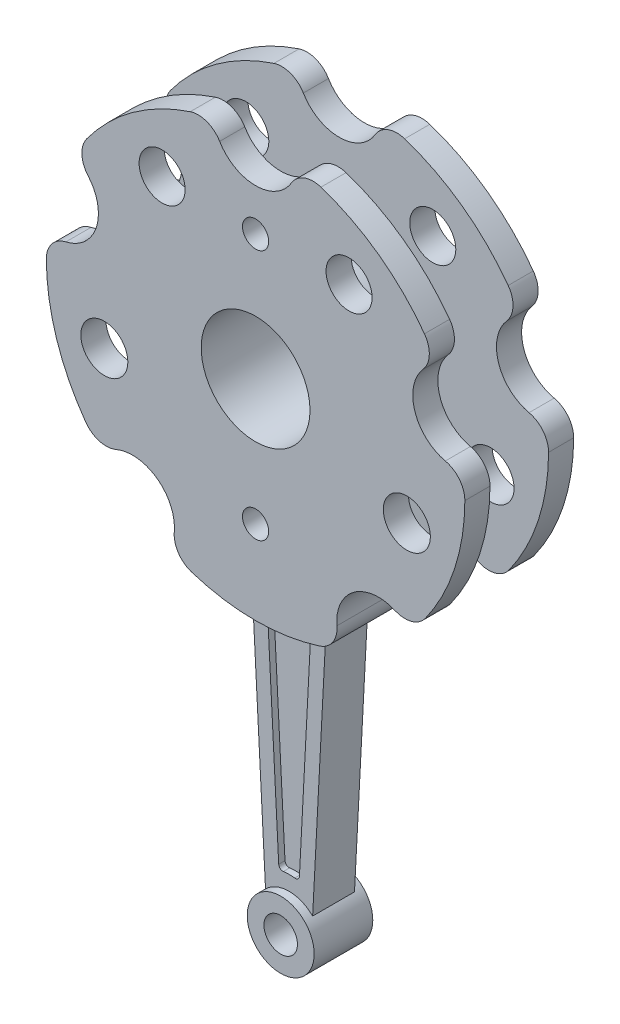
from build123d import *

# Parameters (mm, degrees)
SKETCH1_R           = 13
SKETCH1_R_2         = 3.125
SKETCH1_R_3         = 5.5
SKETCH1_R_4         = 5.616805682
BOSS_EXTRUDE2_DEPTH = 13
SKETCH3_OUTSIDE_W   = 130.454
SKETCH3_OUTSIDE_H   = 128.254
CUT_EXTRUDE2_DEPTH  = 7
BOSS_EXTRUDE3_DEPTH = 3.5
BOSS_EXTRUDE4_DEPTH = 5
SKETCH6_R           = 4
BOSS_EXTRUDE5_DEPTH = 7


with BuildPart() as part:
    # Sketch1 → Boss-Extrude2 (new body, symmetric)
    with BuildSketch(Plane.XY):
        with BuildLine():
            ThreePointArc((45.332150622, 5.700536817), (48.696221254, 3.58439722), (49.999710802, -0.170057869))
            ThreePointArc((49.999710802, -0.170057869), (47.552825815, -15.450849719), (40.55057326, -29.251512923))
            ThreePointArc((40.55057326, -29.251512923), (37.289214732, -31.522758961), (33.323788774, -31.257400752))
            ThreePointArc((33.323788774, -31.257400752), (23.511410092, -32.360679775), (19.42993762, -41.351874493))
            ThreePointArc((19.42993762, -41.351874493), (18.456924262, -45.205218887), (15.289025708, -47.605101543))
            ThreePointArc((15.289025708, -47.605101543), (0, -50), (-15.289025708, -47.605101543))
            ThreePointArc((-15.289025708, -47.605101543), (-18.456924262, -45.205218887), (-19.42993762, -41.351874493))
            ThreePointArc((-19.42993762, -41.351874493), (-23.511410092, -32.360679775), (-33.323788774, -31.257400752))
            ThreePointArc((-33.323788774, -31.257400752), (-37.289214732, -31.522758961), (-40.55057326, -29.251512923))
            ThreePointArc((-40.55057326, -29.251512923), (-47.552825815, -15.450849719), (-49.999710802, -0.170057869))
            ThreePointArc((-49.999710802, -0.170057869), (-48.696221254, 3.58439722), (-45.332150622, 5.700536817))
            ThreePointArc((-45.332150622, 5.700536817), (-38.042260652, 12.360679775), (-40.025171716, 22.033738428))
            ThreePointArc((-40.025171716, 22.033738428), (-41.502926381, 25.72308243), (-40.350658246, 29.526672334))
            ThreePointArc((-40.350658246, 29.526672334), (-29.389262615, 40.450849719), (-15.612494996, 47.5))
            ThreePointArc((-15.612494996, 47.5), (-11.638995596, 47.420498199), (-8.586872248, 44.875))
            ThreePointArc((-8.586872248, 44.875), (0, 40), (8.586872248, 44.875))
            ThreePointArc((8.586872248, 44.875), (11.638995596, 47.420498199), (15.612494996, 47.5))
            ThreePointArc((15.612494996, 47.5), (29.389262615, 40.450849719), (40.350658246, 29.526672334))
            ThreePointArc((40.350658246, 29.526672334), (41.502926381, 25.72308243), (40.025171716, 22.033738428))
            ThreePointArc((40.025171716, 22.033738428), (38.042260652, 12.360679775), (45.332150622, 5.700536817))
        make_face()
        Circle(SKETCH1_R, mode=Mode.SUBTRACT)
        with Locations((0, -30)):
            Circle(SKETCH1_R_2, mode=Mode.SUBTRACT)
        with Locations((0, 30)):
            Circle(SKETCH1_R_2, mode=Mode.SUBTRACT)
        with Locations((22.335839587, 30.742645786)):
            Circle(SKETCH1_R_3, mode=Mode.SUBTRACT)
        with Locations((-22.335839587, 30.742645786)):
            Circle(SKETCH1_R_3, mode=Mode.SUBTRACT)
        with Locations((-36.140147619, -11.742645786)):
            Circle(SKETCH1_R_4, mode=Mode.SUBTRACT)
        with Locations((36.140147619, -11.742645786)):
            Circle(SKETCH1_R_4, mode=Mode.SUBTRACT)
    extrude(amount=BOSS_EXTRUDE2_DEPTH, both=True)

    # Sketch3 outside → Cut-Extrude2 (cut, symmetric)
    with BuildSketch(Plane.XY):
        with Locations((0, -1.1)):
            Rectangle(SKETCH3_OUTSIDE_W, SKETCH3_OUTSIDE_H)
        with BuildLine():
            Line((-12.93127555, -17.798373876), (-23.511410092, -32.360679775))
            ThreePointArc((-23.511410092, -32.360679775), (-20.283525766, -36.317381871), (-19.42993762, -41.351874493))
            ThreePointArc((-19.42993762, -41.351874493), (-18.456924262, -45.205218887), (-15.289025708, -47.605101543))
            ThreePointArc((-15.289025708, -47.605101543), (0, -50), (15.289025708, -47.605101543))
            ThreePointArc((15.289025708, -47.605101543), (18.456924262, -45.205218887), (19.42993762, -41.351874493))
            ThreePointArc((19.42993762, -41.351874493), (20.283525766, -36.317381871), (23.511410092, -32.360679775))
            Line((23.511410092, -32.360679775), (12.93127555, -17.798373876))
            ThreePointArc((12.93127555, -17.798373876), (0, 22), (-12.93127555, -17.798373876))
        make_face(mode=Mode.SUBTRACT)
    extrude(amount=CUT_EXTRUDE2_DEPTH, both=True, mode=Mode.SUBTRACT)



with BuildPart() as body_2:
    # Sketch4 → Boss-Extrude3 (new body, symmetric)
    with BuildSketch(Plane.XY):
        with BuildLine():
            Line((-5.187097318, -53.92545674), (-2.475294912, -105.639894327))
            ThreePointArc((-2.475294912, -105.639894327), (-2.120883278, -106.352371596), (-1.358533599, -106.580525999))
            ThreePointArc((-1.358533599, -106.580525999), (0, -106.5), (1.358533599, -106.580525999))
            ThreePointArc((1.358533599, -106.580525999), (2.120883278, -106.352371596), (2.475294912, -105.639894327))
            Line((2.475294912, -105.639894327), (5.187097318, -53.92545674))
            ThreePointArc((5.187097318, -53.92545674), (4.886610399, -53.157130414), (4.11095631, -52.876099336))
            ThreePointArc((4.11095631, -52.876099336), (0, -53.035665761), (-4.11095631, -52.876099336))
            ThreePointArc((-4.11095631, -52.876099336), (-4.886610399, -53.157130414), (-5.187097318, -53.92545674))
        make_face()
    extrude(amount=BOSS_EXTRUDE3_DEPTH, both=True)


with BuildPart() as part_1:
    add(part.part)

    add(body_2.part)  # Boss-Extrude4 merges body 2
    # Sketch5 → Boss-Extrude4 (add, symmetric)
    with BuildSketch(Plane.XY):
        with BuildLine():
            ThreePointArc((8.94, -49.194272024), (0, -50), (-8.94, -49.194272024))
            Line((-8.94, -49.194272024), (-5.63, -112.316418383))
            ThreePointArc((-5.63, -112.316418383), (0, -110), (5.63, -112.316418383))
            Line((5.63, -112.316418383), (8.94, -49.194272024))
        make_face()
        with BuildLine():
            Line((-2.475294912, -105.639894327), (-5.187097318, -53.92545674))
            ThreePointArc((-5.187097318, -53.92545674), (-4.886610399, -53.157130414), (-4.11095631, -52.876099336))
            ThreePointArc((-4.11095631, -52.876099336), (0, -53.035665761), (4.11095631, -52.876099336))
            ThreePointArc((4.11095631, -52.876099336), (4.886610399, -53.157130414), (5.187097318, -53.92545674))
            Line((5.187097318, -53.92545674), (2.475294912, -105.639894327))
            ThreePointArc((2.475294912, -105.639894327), (2.120883278, -106.352371596), (1.358533599, -106.580525999))
            ThreePointArc((1.358533599, -106.580525999), (0, -106.5), (-1.358533599, -106.580525999))
            ThreePointArc((-1.358533599, -106.580525999), (-2.120883278, -106.352371596), (-2.475294912, -105.639894327))
        make_face(mode=Mode.SUBTRACT)
    extrude(amount=BOSS_EXTRUDE4_DEPTH, both=True)

    # Sketch6 → Boss-Extrude5 (add, symmetric)
    with BuildSketch(Plane.XY):
        with BuildLine():
            ThreePointArc((5.63, -112.316418383), (0, -110), (-5.63, -112.316418383))
            ThreePointArc((-5.63, -112.316418383), (-3.078960864, -125.383765977), (8, -118))
            ThreePointArc((8, -118), (7.383765977, -114.921039136), (5.63, -112.316418383))
        make_face()
        with Locations((0, -118)):
            Circle(SKETCH6_R, mode=Mode.SUBTRACT)
    extrude(amount=BOSS_EXTRUDE5_DEPTH, both=True)


solid = part_1.part
